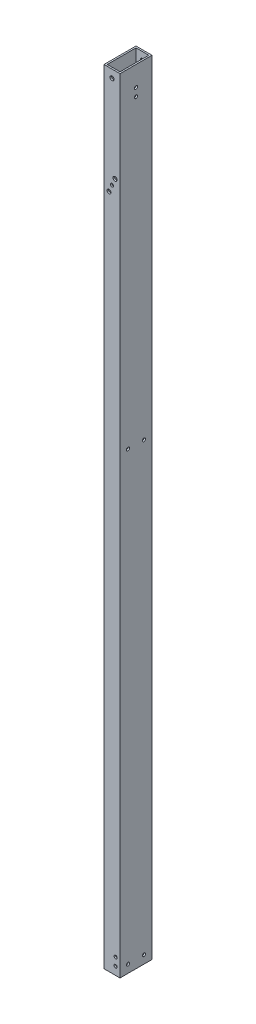
from build123d import *

# Parameters (mm, degrees)
SKETCH1_W           = 25.4
SKETCH1_H           = 50.8
SKETCH1_W_2         = 20.32
SKETCH1_H_2         = 45.72
EXTRUDE_THIN1_DEPTH = 1244.6
SKETCH3_R           = 2.4892
SKETCH3_R_2         = 2.5019
CUT_EXTRUDE1_DEPTH  = 26.4
SKETCH4_R           = 2.4892
CUT_EXTRUDE2_DEPTH  = 26.4
SKETCH8_R           = 2.4892
CUT_EXTRUDE4_DEPTH  = 51.8
SKETCH11_R          = 2.4892
CUT_EXTRUDE6_DEPTH  = 51.8
SKETCH12_R          = 3.175
CUT_EXTRUDE7_DEPTH  = 51.8
SKETCH13_R          = 3.175
CUT_EXTRUDE8_DEPTH  = 51.8


with BuildPart() as part:
    # Sketch1 → Extrude-Thin1 (new body)
    with BuildSketch(Plane(origin=(0, 0, 0), x_dir=(1, 0, 0), z_dir=(0, 1, 0))):
        with Locations((12.7, 25.4)):
            Rectangle(SKETCH1_W, SKETCH1_H)
        with Locations((12.7, 25.4)):
            Rectangle(SKETCH1_W_2, SKETCH1_H_2, mode=Mode.SUBTRACT)
    extrude(amount=EXTRUDE_THIN1_DEPTH)

    # Sketch3 → Cut-Extrude1 (cut, through all)
    with BuildSketch(Plane(origin=(25.4, 0, 0), x_dir=(0, 0, -1), z_dir=(1, 0, 0))):
        with Locations((12.7, 12.7)):
            Circle(SKETCH3_R)
        with Locations((38.1, 12.960193373)):
            Circle(SKETCH3_R)
        with Locations((12.7, 721.632068306)):
            Circle(SKETCH3_R_2)
        with Locations((38.1, 721.632068306)):
            Circle(SKETCH3_R_2)
    extrude(amount=-CUT_EXTRUDE1_DEPTH, mode=Mode.SUBTRACT)

    # Sketch4 → Cut-Extrude2 (cut, through all)
    with BuildSketch(Plane.ZY):
        with Locations((-25.4, 1200.15)):
            Circle(SKETCH4_R)
        with Locations((-25.4, 1212.85)):
            Circle(SKETCH4_R)
    extrude(amount=-CUT_EXTRUDE2_DEPTH, mode=Mode.SUBTRACT)

    # Sketch8 → Cut-Extrude4 (cut, through all)
    with BuildSketch(Plane(origin=(0, 0, -50.8), x_dir=(-1, 0, 0), z_dir=(0, 0, -1))):
        with Locations((-12.7, 1084.8045868)):
            Circle(SKETCH8_R)
    extrude(amount=-CUT_EXTRUDE4_DEPTH, mode=Mode.SUBTRACT)

    # Sketch11 → Cut-Extrude6 (cut, through all)
    with BuildSketch(Plane.XY):
        with Locations((18.415, 12.7)):
            Circle(SKETCH11_R)
        with Locations((18.415, 25.4)):
            Circle(SKETCH11_R)
    extrude(amount=-CUT_EXTRUDE6_DEPTH, mode=Mode.SUBTRACT)

    # Sketch12 → Cut-Extrude7 (cut, through all)
    with BuildSketch(Plane(origin=(0, 0, -50.8), x_dir=(-1, 0, 0), z_dir=(0, 0, -1))):
        with Locations((-12.7, 1231.9)):
            Circle(SKETCH12_R)
    extrude(amount=-CUT_EXTRUDE7_DEPTH, mode=Mode.SUBTRACT)

    # Sketch13 → Cut-Extrude8 (cut, through all)
    with BuildSketch(Plane(origin=(0, 0, -50.8), x_dir=(-1, 0, 0), z_dir=(0, 0, -1))):
        with Locations((-17.4625, 1095.9170868)):
            Circle(SKETCH13_R)
        with Locations((-7.9375, 1073.6920868)):
            Circle(SKETCH13_R)
    extrude(amount=-CUT_EXTRUDE8_DEPTH, mode=Mode.SUBTRACT)


solid = part.part
